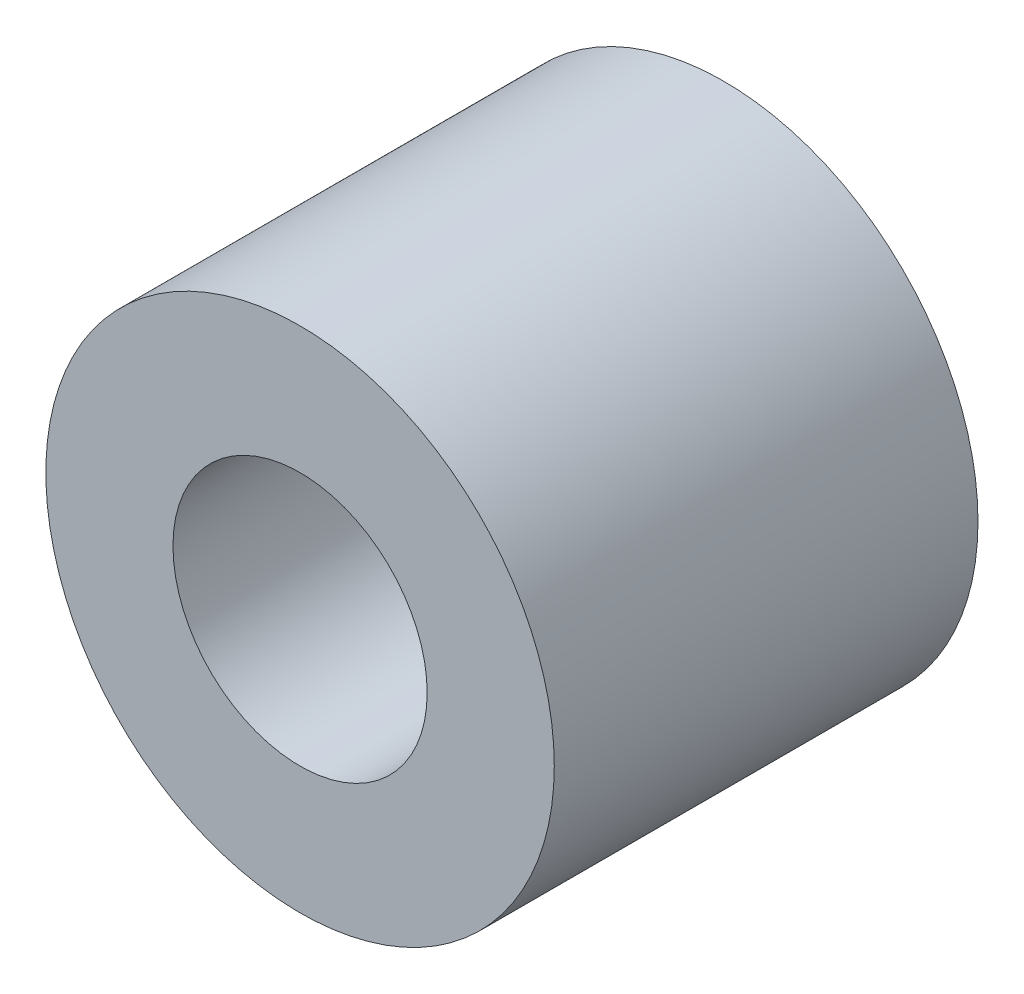
from build123d import *

# Parameters (mm, degrees)
SKETCH2_R           = 3
SKETCH2_R_2         = 1.5
BOSS_EXTRUDE1_DEPTH = 5


with BuildPart() as part:
    # Sketch2 → Boss-Extrude1 (new body)
    with BuildSketch(Plane.XY):
        Circle(SKETCH2_R)
        Circle(SKETCH2_R_2, mode=Mode.SUBTRACT)
    extrude(amount=BOSS_EXTRUDE1_DEPTH)


solid = part.part
